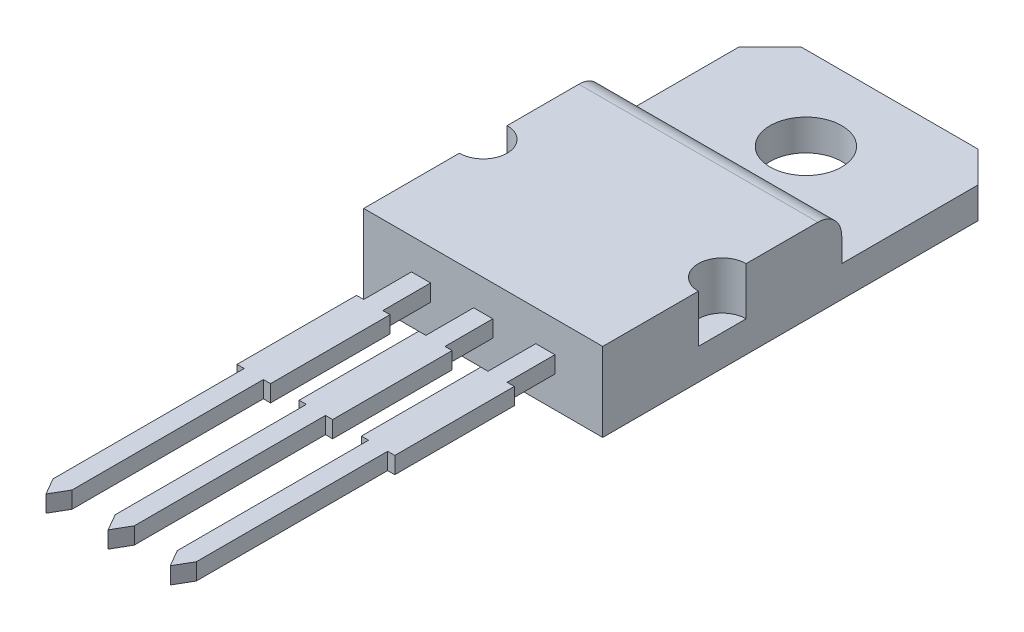
from build123d import *

# Parameters (mm, degrees)
BOSS_EXTRUDE1_DEPTH   = 0.7
BOSS_EXTRUDE1_2_DEPTH = 0.7
BOSS_EXTRUDE1_3_DEPTH = 0.7
SKETCH2_W             = 10
SKETCH2_H             = 10
BOSS_EXTRUDE2_DEPTH   = 2
FILLET1_R             = 1
SKETCH3_R             = 1
CUT_EXTRUDE1_DEPTH    = 2
BOSS_EXTRUDE3_DEPTH   = 1.3
SKETCH5_R             = 1.5
CUT_EXTRUDE2_DEPTH    = 2.3


with BuildPart() as part:
    # Sketch1 → Boss-Extrude1 (new body)
    with BuildSketch(Plane(origin=(0, 0, 0), x_dir=(1, 0, 0), z_dir=(0, 1, 0))):
        Polygon((0, 0), (0, 8), (-0.3, 8), (-0.3, 13), (0, 13), (0, 15), (0.8, 15), (0.8, 13), (1.1, 13), (1.1, 8), (0.8, 8), (0.8, 0), (0.4, -0.692820323), align=None)
    extrude(amount=BOSS_EXTRUDE1_DEPTH)



with BuildPart() as body_2:
    # Sketch1 → Boss-Extrude1 2 (new body)
    with BuildSketch(Plane(origin=(0, 0, 0), x_dir=(1, 0, 0), z_dir=(0, 1, 0))):
        Polygon((-1.8, 15), (-2.6, 15), (-2.6, 13), (-2.9, 13), (-2.9, 8), (-2.6, 8), (-2.6, 0), (-2.2, -0.692820323), (-1.8, 0), (-1.8, 8), (-1.5, 8), (-1.5, 13), (-1.8, 13), align=None)
    extrude(amount=BOSS_EXTRUDE1_2_DEPTH)


with BuildPart() as body_3:
    # Sketch1 → Boss-Extrude1 3 (new body)
    with BuildSketch(Plane(origin=(0, 0, 0), x_dir=(1, 0, 0), z_dir=(0, 1, 0))):
        Polygon((-5.5, 13), (-5.5, 8), (-5.2, 8), (-5.2, 0), (-4.8, -0.692820323), (-4.4, 0), (-4.4, 8), (-4.1, 8), (-4.1, 13), (-4.4, 13), (-4.4, 15), (-5.2, 15), (-5.2, 13), align=None)
    extrude(amount=BOSS_EXTRUDE1_3_DEPTH)


with BuildPart() as part_1:
    add(part.part)

    add(body_2.part)  # Boss-Extrude2 merges body 2

    add(body_3.part)  # Boss-Extrude2 merges body 3
    # Sketch2 → Boss-Extrude2 (add)
    with BuildSketch(Plane(origin=(0, 0, 0), x_dir=(1, 0, 0), z_dir=(0, 1, 0))):
        with Locations((-2.2, 20)):
            Rectangle(SKETCH2_W, SKETCH2_H)
    extrude(amount=BOSS_EXTRUDE2_DEPTH)

    # Fillet1
    fillet1_edges = [part_1.edges().sort_by_distance(p)[0] for p in [
        (-2.2, 2, -25),
    ]]
    fillet(fillet1_edges, radius=FILLET1_R)

    # Sketch3 → Cut-Extrude1 (cut)
    with BuildSketch(Plane(origin=(0, 2, 0), x_dir=(1, 0, 0), z_dir=(0, 1, 0))):
        with Locations((-7.2, 20)):
            Circle(SKETCH3_R)
        with Locations((2.8, 20)):
            Circle(SKETCH3_R)
    extrude(amount=-CUT_EXTRUDE1_DEPTH, mode=Mode.SUBTRACT)

    # Sketch4 → Boss-Extrude3 (add)
    with BuildSketch(Plane.XZ):
        Polygon((-7.2, -30.7), (-5.9, -32), (1.5, -32), (2.8, -30.7), (2.8, -15), (-7.2, -15), align=None)
    extrude(amount=BOSS_EXTRUDE3_DEPTH)

    # Sketch5 → Cut-Extrude2 (cut, through all)
    with BuildSketch(Plane(origin=(0, 0, 0), x_dir=(1, 0, 0), z_dir=(0, 1, 0))):
        with Locations((-2.2, 28.5)):
            Circle(SKETCH5_R)
    extrude(amount=-CUT_EXTRUDE2_DEPTH, mode=Mode.SUBTRACT)


solid = part_1.part
